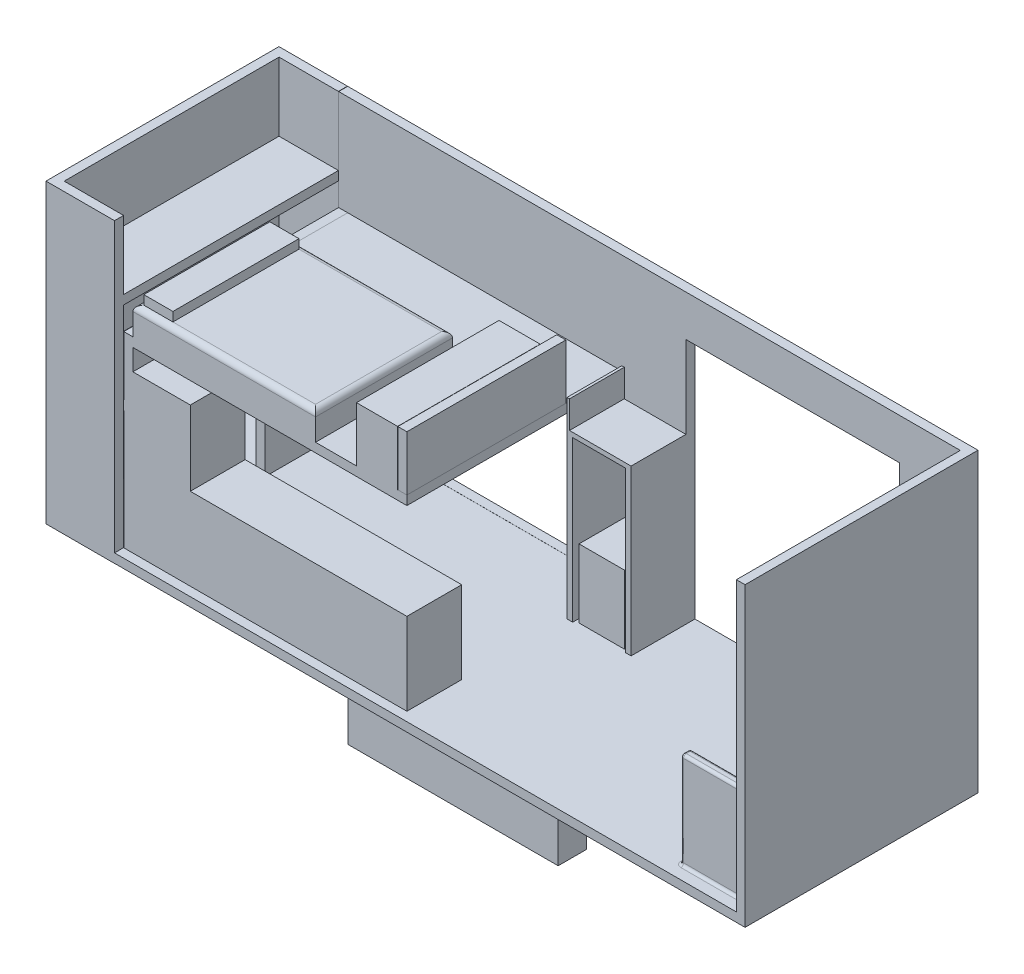
from build123d import *

# Parameters (mm, degrees)
BOSS_EXTRUDE1_DEPTH  = 100.584
SKETCH3_W            = 7010.4
SKETCH3_H            = 100.584
BOSS_EXTRUDE2_DEPTH  = 3200.4
SKETCH4_W            = 100.584
SKETCH4_H            = 2389.632
BOSS_EXTRUDE3_DEPTH  = 2082.799999898
SKETCH5_W            = 3048
SKETCH5_H            = 609.6
BOSS_EXTRUDE4_DEPTH  = 914.4
SKETCH6_W            = 762
SKETCH6_H            = 1828.8
CUT_EXTRUDE1_DEPTH   = 179.07
SKETCH7_W            = 762
SKETCH7_H            = 2389.632
BOSS_EXTRUDE5_DEPTH  = 1066.8
SKETCH8_W            = 609.6
SKETCH8_H            = 2084.832
CUT_EXTRUDE2_DEPTH   = 609.6
SKETCH9_W            = 762
SKETCH9_H            = 48.768
CUT_EXTRUDE3_DEPTH   = 1066.8
FILLET1_R            = 30.48
SKETCH11_W           = 2389.632
SKETCH11_H           = 101.58984
BOSS_EXTRUDE6_DEPTH  = 3048
SKETCH12_W           = 100.584
SKETCH12_H           = 1767.84
BOSS_EXTRUDE7_DEPTH  = 609.6
SKETCH14_W           = 3048
SKETCH14_H           = 1980.184000102
CUT_EXTRUDE4_DEPTH   = 121.92
BOSS_EXTRUDE8_DEPTH  = 609.6
SKETCH16_W           = 64.008
SKETCH16_H           = 1828.8
BOSS_EXTRUDE9_DEPTH  = 609.6
SKETCH17_W           = 2377.44
SKETCH17_H           = 2743.2
CUT_EXTRUDE5_DEPTH   = 609.6
SKETCH20_W           = 762
SKETCH20_H           = 2590.8
BOSS_EXTRUDE10_DEPTH = 3200.4
SKETCH23_W           = 660.41016
SKETCH23_H           = 2389.632
CUT_EXTRUDE6_DEPTH   = 3200.4
SKETCH24_W           = 764.655724872
SKETCH24_H           = 2590.8
BOSS_EXTRUDE11_DEPTH = 101.598984
SKETCH25_W           = 762
SKETCH25_H           = 1584.96
CUT_EXTRUDE7_DEPTH   = 101.598984
SKETCH26_W           = 660.41016
SKETCH26_H           = 100.584
BOSS_EXTRUDE12_DEPTH = 2427.984984
SKETCH27_W           = 2389.632
SKETCH27_H           = 100.584
BOSS_EXTRUDE13_DEPTH = 703.326
SKETCH28_W           = 2031.7968
SKETCH28_H           = 1524
BOSS_EXTRUDE14_DEPTH = 304.8
FILLET2_R            = 60.96
SKETCH29_W           = 323.869500016
SKETCH29_H           = 1402.08
BOSS_EXTRUDE15_DEPTH = 101.4984
SKETCH30_W           = 457.2
SKETCH30_H           = 1584.96
BOSS_EXTRUDE16_DEPTH = 609.6
SKETCH32_W           = 505.94565908
SKETCH32_H           = 582.037684295
BOSS_EXTRUDE25_DEPTH = 762
SKETCH33_W           = 96.402821382
SKETCH33_H           = 2490.216
BOSS_EXTRUDE26_DEPTH = 3200.4
SKETCH34_R           = 27.448199129
BOSS_EXTRUDE27_DEPTH = 631.444
SKETCH35_W           = 639.143683672
SKETCH35_H           = 609.6
BOSS_EXTRUDE28_DEPTH = 831.088
SKETCH36_W           = 517.132618211
SKETCH36_H           = 1532.194064783
CUT_EXTRUDE9_DEPTH   = 507.238
SKETCH37_W           = 2339.621689526
SKETCH37_H           = 316.294331202
SKETCH37_H_2         = 353.925095988
BOSS_EXTRUDE29_DEPTH = 507.238


with BuildPart() as part:
    # Sketch1 → Boss-Extrude1 (new body)
    with BuildSketch(Plane(origin=(0, 0, 0), x_dir=(1, 0, 0), z_dir=(0, 1, 0))):
        Polygon((0, 0), (0, 418.290787275), (-1219.2, 1295.4), (0, 2172.509212725), (0, 2590.8), (7010.4, 2590.8), (7010.4, 0), align=None)
    extrude(amount=BOSS_EXTRUDE1_DEPTH)

    # Sketch3 → Boss-Extrude2 (add)
    with BuildSketch(Plane(origin=(0, 100.584, 0), x_dir=(1, 0, 0), z_dir=(0, 1, 0))):
        with Locations((3505.2, 2540.508)):
            Rectangle(SKETCH3_W, SKETCH3_H)
    extrude(amount=BOSS_EXTRUDE2_DEPTH)

    # Sketch4 → Boss-Extrude3 (add)
    with BuildSketch(Plane(origin=(0, 100.584, 0), x_dir=(1, 0, 0), z_dir=(0, 1, 0))):
        with Locations((50.292, 1295.4)):
            Rectangle(SKETCH4_W, SKETCH4_H)
    extrude(amount=BOSS_EXTRUDE3_DEPTH)

    # Sketch5 → Boss-Extrude4 (add)
    with BuildSketch(Plane(origin=(0, 100.584, 0), x_dir=(1, 0, 0), z_dir=(0, 1, 0))):
        with Locations((1624.584, 405.384)):
            Rectangle(SKETCH5_W, SKETCH5_H)
    extrude(amount=BOSS_EXTRUDE4_DEPTH)

    # Sketch6 → Cut-Extrude1 (cut)
    with BuildSketch(Plane(origin=(0, 0, 0), x_dir=(0, 0, -1), z_dir=(1, 0, 0))):
        with Locations((1188.929954617, 1012.196870273)):
            Rectangle(SKETCH6_W, SKETCH6_H)
    extrude(amount=CUT_EXTRUDE1_DEPTH, mode=Mode.SUBTRACT)

    # Sketch7 → Boss-Extrude5 (add)
    with BuildSketch(Plane(origin=(0, 100.584, 0), x_dir=(1, 0, 0), z_dir=(0, 1, 0))):
        with Locations((6527.79997968, 1295.4)):
            Rectangle(SKETCH7_W, SKETCH7_H)
    extrude(amount=BOSS_EXTRUDE5_DEPTH)

    # Sketch8 → Cut-Extrude2 (cut)
    with BuildSketch(Plane(origin=(0, 1167.384, 0), x_dir=(1, 0, 0), z_dir=(0, 1, 0))):
        with Locations((6451.59997968, 1295.4)):
            Rectangle(SKETCH8_W, SKETCH8_H)
    extrude(amount=-CUT_EXTRUDE2_DEPTH, mode=Mode.SUBTRACT)

    # Sketch9 → Cut-Extrude3 (cut)
    with BuildSketch(Plane(origin=(0, 1167.384, 0), x_dir=(1, 0, 0), z_dir=(0, 1, 0))):
        with Locations((6527.79997968, 2465.832)):
            Rectangle(SKETCH9_W, SKETCH9_H)
        with Locations((6527.79997968, 124.968)):
            Rectangle(SKETCH9_W, SKETCH9_H)
    extrude(amount=-CUT_EXTRUDE3_DEPTH, mode=Mode.SUBTRACT)

    # Fillet1
    fillet1_edges = [part.edges().sort_by_distance(p)[0] for p in [
        (6146.79997968, 1167.384, -201.168),
        (6146.79997968, 557.784, -1295.4),
        (6146.79997968, 862.584, -252.984),
        (6451.59997968, 557.784, -2337.816),
        (6146.79997968, 862.584, -2337.816),
        (6756.39997968, 557.784, -1295.4),
        (6756.39997968, 862.584, -2337.816),
        (6451.59997968, 557.784, -252.984),
        (6756.39997968, 862.584, -252.984),
        (6451.59997968, 1167.384, -252.984),
        (6756.39997968, 1167.384, -1295.4),
        (6451.59997968, 1167.384, -2337.816),
        (6146.79997968, 1167.384, -2389.632),
        (6146.79997968, 100.584, -1295.4),
        (6146.79997968, 633.984, -2441.448),
        (6527.79997968, 100.584, -2441.448),
        (6527.79997968, 1167.384, -2441.448),
        (6908.79997968, 1167.384, -1295.4),
        (6527.79997968, 100.584, -149.352),
        (6146.79997968, 633.984, -149.352),
        (6527.79997968, 1167.384, -149.352),
    ]]
    fillet(fillet1_edges, radius=FILLET1_R)

    # Sketch11 → Boss-Extrude6 (add)
    with BuildSketch(Plane(origin=(100.584, 0, 0), x_dir=(0, 0, -1), z_dir=(1, 0, 0))):
        with Locations((1295.4, 2132.57892)):
            Rectangle(SKETCH11_W, SKETCH11_H)
    extrude(amount=BOSS_EXTRUDE6_DEPTH)

    # Sketch14 → Cut-Extrude4 (cut)
    with BuildSketch(Plane(origin=(0, 0, -2590.8), x_dir=(-1, 0, 0), z_dir=(0, 0, -1))):
        with Locations((-1625.4984, 1091.691999949)):
            Rectangle(SKETCH14_W, SKETCH14_H)
    extrude(amount=-CUT_EXTRUDE4_DEPTH, mode=Mode.SUBTRACT)

    # Sketch15 → Boss-Extrude8 (add)
    with BuildSketch(Plane.XY.offset(-2490.216)):
        Polygon((3176.9304, 1929.384), (3798.1128, 1929.384), (3798.1128, 1878.57384), (3212.8968, 1878.57384), (3212.8968, 100.584), (3149.4984, 100.584), (3149.4984, 1878.57384), (3149.4984, 1929.384), (3149.4984, 2234.184), (3176.9304, 2234.184), align=None)
    extrude(amount=BOSS_EXTRUDE8_DEPTH)

    # Sketch16 → Boss-Extrude9 (add)
    with BuildSketch(Plane.XY.offset(-2490.216)):
        with Locations((3830.1168, 1014.984)):
            Rectangle(SKETCH16_W, SKETCH16_H)
    extrude(amount=BOSS_EXTRUDE9_DEPTH)

    # Sketch17 → Cut-Extrude5 (cut)
    with BuildSketch(Plane.XY.offset(-2490.216)):
        with Locations((5050.8408, 1472.184)):
            Rectangle(SKETCH17_W, SKETCH17_H)
    extrude(amount=-CUT_EXTRUDE5_DEPTH, mode=Mode.SUBTRACT)

    # Sketch20 → Boss-Extrude10 (add)
    with BuildSketch(Plane(origin=(0, 100.584, 0), x_dir=(1, 0, 0), z_dir=(0, 1, 0))):
        with Locations((-383.655724872, 1295.4)):
            Rectangle(SKETCH20_W, SKETCH20_H)
    extrude(amount=BOSS_EXTRUDE10_DEPTH)

    # Sketch23 → Cut-Extrude6 (cut)
    with BuildSketch(Plane(origin=(0, 3300.984, 0), x_dir=(1, 0, 0), z_dir=(0, 1, 0))):
        with Locations((-332.860804872, 1295.4)):
            Rectangle(SKETCH23_W, SKETCH23_H)
    extrude(amount=-CUT_EXTRUDE6_DEPTH, mode=Mode.SUBTRACT)

    # Sketch24 → Boss-Extrude11 (add)
    with BuildSketch(Plane.XZ.offset(-100.584)):
        with Locations((-382.327862436, -1295.4)):
            Rectangle(SKETCH24_W, SKETCH24_H)
    extrude(amount=BOSS_EXTRUDE11_DEPTH)

    # Sketch25 → Cut-Extrude7 (cut)
    with BuildSketch(Plane.ZY.offset(764.655724872)):
        with Locations((-1929.378363182, 900.571886789)):
            Rectangle(SKETCH25_W, SKETCH25_H)
    extrude(amount=-CUT_EXTRUDE7_DEPTH, mode=Mode.SUBTRACT)

    # Sketch26 → Boss-Extrude12 (add)
    with BuildSketch(Plane(origin=(0, 0, -100.584), x_dir=(-1, 0, 0), z_dir=(0, 0, -1))):
        with Locations((332.860804872, 2488.692)):
            Rectangle(SKETCH26_W, SKETCH26_H)
    extrude(amount=BOSS_EXTRUDE12_DEPTH)

    # Sketch27 → Boss-Extrude13 (add)
    with BuildSketch(Plane.ZY):
        with Locations((-1295.4, 1473.708)):
            Rectangle(SKETCH27_W, SKETCH27_H)
    extrude(amount=BOSS_EXTRUDE13_DEPTH)

    # Sketch28 → Boss-Extrude14 (add)
    with BuildSketch(Plane(origin=(0, 2183.37384, 0), x_dir=(1, 0, 0), z_dir=(0, 1, 0))):
        with Locations((1116.4824, 862.584)):
            Rectangle(SKETCH28_W, SKETCH28_H)
    extrude(amount=BOSS_EXTRUDE14_DEPTH)

    # Fillet2
    fillet2_edges = [part.edges().sort_by_distance(p)[0] for p in [
        (100.584, 2488.17384, -862.584),
        (1116.4824, 2488.17384, -100.584),
        (2132.3808, 2488.17384, -862.584),
        (1116.4824, 2488.17384, -1624.584),
    ]]
    fillet(fillet2_edges, radius=FILLET2_R)

    # Sketch29 → Boss-Extrude15 (add)
    with BuildSketch(Plane(origin=(0, 2488.17384, 0), x_dir=(1, 0, 0), z_dir=(0, 1, 0))):
        with Locations((323.478750008, 862.584)):
            Rectangle(SKETCH29_W, SKETCH29_H)
    extrude(amount=BOSS_EXTRUDE15_DEPTH)

    # Sketch30 → Boss-Extrude16 (add)
    with BuildSketch(Plane(origin=(0, 2183.37384, 0), x_dir=(1, 0, 0), z_dir=(0, 1, 0))):
        with Locations((2816.80125235, 893.064)):
            Rectangle(SKETCH30_W, SKETCH30_H)
    extrude(amount=BOSS_EXTRUDE16_DEPTH)

    # Sketch32 → Boss-Extrude25 (add)
    with BuildSketch(Plane(origin=(0, 100.584, 0), x_dir=(1, 0, 0), z_dir=(0, 1, 0))):
        with Locations((3508.478278258, 2199.197157853)):
            Rectangle(SKETCH32_W, SKETCH32_H)
    extrude(amount=BOSS_EXTRUDE25_DEPTH)

    # Sketch33 → Boss-Extrude26 (add)
    with BuildSketch(Plane(origin=(0, 100.584, 0), x_dir=(1, 0, 0), z_dir=(0, 1, 0))):
        with Locations((6962.198589309, 1245.108)):
            Rectangle(SKETCH33_W, SKETCH33_H)
    extrude(amount=BOSS_EXTRUDE26_DEPTH)

    # Sketch34 → Boss-Extrude27 (add)
    with BuildSketch(Plane(origin=(3212.8968, 0, 0), x_dir=(0, 0, -1), z_dir=(1, 0, 0))):
        with Locations(Location((2218.07408082, 1812.870118347, 0), (0, 0, 270))):  # turned: the seam where the file's is
            Circle(SKETCH34_R)
    extrude(amount=BOSS_EXTRUDE27_DEPTH)

    # Sketch35 → Boss-Extrude28 (add)
    with BuildSketch(Plane(origin=(0, 1014.984, 0), x_dir=(1, 0, 0), z_dir=(0, 1, 0))):
        with Locations((420.155841836, 405.384)):
            Rectangle(SKETCH35_W, SKETCH35_H)
    extrude(amount=BOSS_EXTRUDE28_DEPTH)

    # Sketch36 → Cut-Extrude9 (cut)
    with BuildSketch(Plane(origin=(0, 0, -710.184), x_dir=(-1, 0, 0), z_dir=(0, 0, -1))):
        with Locations((-420.62647127, 1016.064605357)):
            Rectangle(SKETCH36_W, SKETCH36_H)
    extrude(amount=-CUT_EXTRUDE9_DEPTH, mode=Mode.SUBTRACT)

    # Sketch37 → Boss-Extrude29 (add)
    with BuildSketch(Plane.XZ):
        with Locations((3700.666319437, -219.459647699)):
            Rectangle(SKETCH37_W, SKETCH37_H)
        with Locations((3700.666319437, -2359.140520545)):
            Rectangle(SKETCH37_W, SKETCH37_H_2)
    extrude(amount=BOSS_EXTRUDE29_DEPTH)


with BuildPart() as body_2:
    # Sketch12 → Boss-Extrude7 (new body)
    with BuildSketch(Plane(origin=(0, 2183.383999898, 0), x_dir=(1, 0, 0), z_dir=(0, 1, 0))):
        with Locations((3098.292, 984.504)):
            Rectangle(SKETCH12_W, SKETCH12_H)
    extrude(amount=BOSS_EXTRUDE7_DEPTH)


solid = Compound([part.part, body_2.part])
